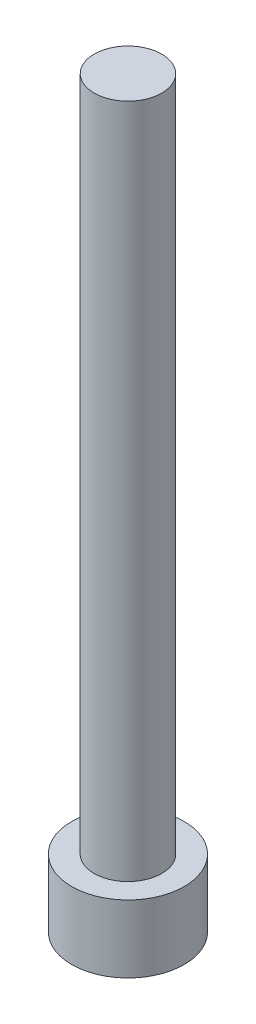
from build123d import *

# Parameters (mm, degrees)
SKETCH_1_R          = 2.5
EXTRUDE_1_DEPTH     = 3
SKETCH_2_R          = 1.5
EXTRUDE_2_DEPTH     = 30
CUT_EXTRUDE_1_DEPTH = 1.65


with BuildPart() as part:
    # 草图1 → 凸台-拉伸1 (new body)
    with BuildSketch(Plane(origin=(0, 0, 0), x_dir=(1, 0, 0), z_dir=(0, 1, 0))):
        Circle(SKETCH_1_R)
    extrude(amount=EXTRUDE_1_DEPTH)

    # 草图2 → 凸台-拉伸2 (add)
    with BuildSketch(Plane(origin=(0, 3, 0), x_dir=(1, 0, 0), z_dir=(0, 1, 0))):
        Circle(SKETCH_2_R)
    extrude(amount=EXTRUDE_2_DEPTH)

    # 草图3 → 切除-拉伸1 (cut)
    with BuildSketch(Plane.XZ):
        Polygon((1.425, 0), (0.7125, 1.2340862), (-0.7125, 1.2340862), (-1.425, 0), (-0.7125, -1.2340862), (0.7125, -1.2340862), align=None)
    extrude(amount=-CUT_EXTRUDE_1_DEPTH, mode=Mode.SUBTRACT)


solid = part.part
